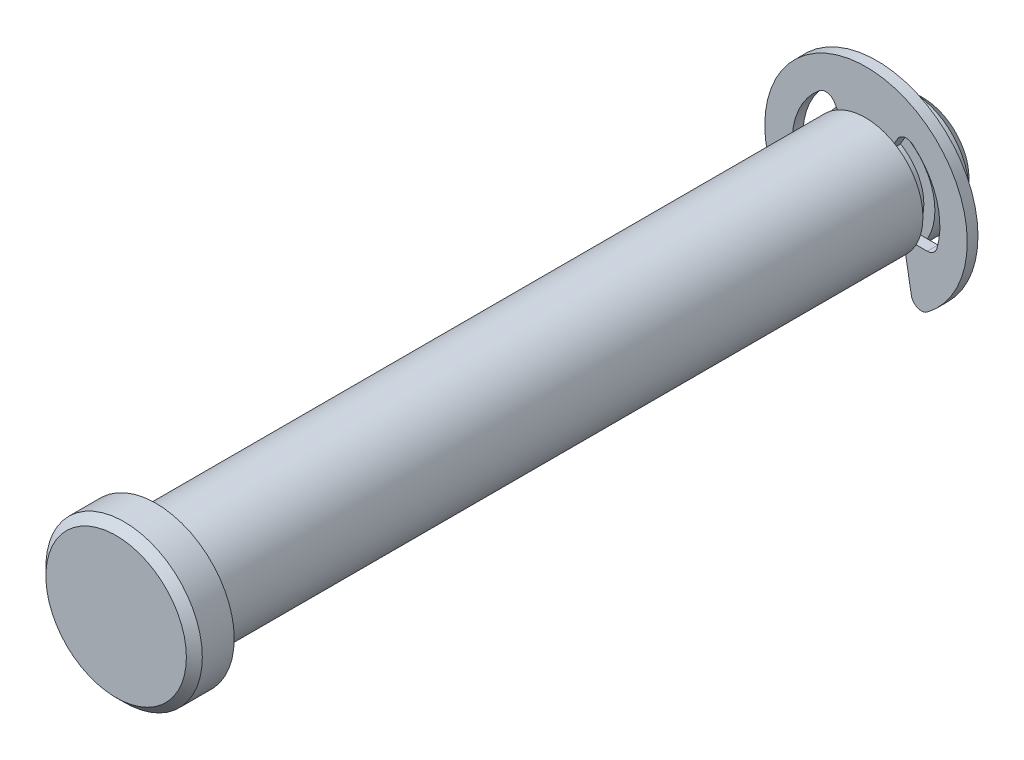
from build123d import *

# Parameters (mm, degrees)
SKETCH2_R      = 4.7625
EXTRUDE1_DEPTH = 31.75
SKETCH3_W      = 0.9906
SKETCH3_H      = 0.9144
SKETCH8_R      = 6.477
EXTRUDE6_DEPTH = 3.302
CHAMFER2_SIZE  = 0.6604
SKETCH4_R      = 8.382
SKETCH4_R_2    = 3.8481
EXTRUDE2_DEPTH = 0.4445
EXTRUDE4_DEPTH = 32.75
EXTRUDE5_DEPTH = 0.889
FILLET1_R      = 0.8382
CHAMFER1_SIZE  = 0.9525


with BuildPart() as part:
    # Sketch2 → Extrude1 (new body, symmetric)
    with BuildSketch(Plane.XY):
        Circle(SKETCH2_R)
    extrude(amount=EXTRUDE1_DEPTH, both=True)

    # Sketch3 → Cut-Revolve1 (revolve, cut)
    with BuildSketch(Plane(origin=(0, 0, 0), x_dir=(0, 0, -1), z_dir=(1, 0, 0))):
        with Locations((27.4828, 4.3053)):
            Rectangle(SKETCH3_W, SKETCH3_H)
    revolve(axis=Axis((0, 0, 31.75), (0, 0, -1)), mode=Mode.SUBTRACT)

    # Sketch8 → Extrude6 (add)
    with BuildSketch(Plane.XY.offset(31.75)):
        Circle(SKETCH8_R)
    extrude(amount=EXTRUDE6_DEPTH)

    # Chamfer2
    chamfer2_edges = [part.edges().sort_by_distance(p)[0] for p in [
        (-6.477, 0, 35.052),
    ]]
    chamfer(chamfer2_edges, length=CHAMFER2_SIZE)

    # Chamfer1
    chamfer1_edges = [part.edges().sort_by_distance(p)[0] for p in [
        (-4.7625, 0, -31.75),
    ]]
    chamfer(chamfer1_edges, length=CHAMFER1_SIZE)


with BuildPart() as body_2:
    # Sketch4 → Extrude2 (new body, symmetric)
    with BuildSketch(Plane.XY.offset(-27.4828)):
        Circle(SKETCH4_R)
        Circle(SKETCH4_R_2, mode=Mode.SUBTRACT)
    extrude(amount=EXTRUDE2_DEPTH, both=True)

    # Sketch5 → Extrude4 (cut, through all)
    with BuildSketch(Plane.XY):
        with BuildLine():
            Line((-3.057525, 5.295788645), (0, 0))
            Line((0, 0), (3.057525, 5.295788645))
            ThreePointArc((3.057525, 5.295788645), (5.785069674, 1.981616859), (5.662420154, -2.30886))
            Line((5.662420154, -2.30886), (3.07848, -2.30886))
            Line((3.07848, -2.30886), (3.972784338, -7.380711931))
            ThreePointArc((3.972784338, -7.380711931), (0, -8.382), (-3.972784338, -7.380711931))
            Line((-3.972784338, -7.380711931), (-3.07848, -2.30886))
            Line((-3.07848, -2.30886), (-5.662420154, -2.30886))
            ThreePointArc((-5.662420154, -2.30886), (-5.785069674, 1.981616859), (-3.057525, 5.295788645))
        make_face()
    extrude(amount=-EXTRUDE4_DEPTH, mode=Mode.SUBTRACT)

    # Sketch6 → Extrude5 (add)
    with BuildSketch(Plane.XY.offset(-27.0383)):
        with BuildLine():
            Line((-1.92405, 3.332552356), (1.92405, 3.332552356))
            ThreePointArc((1.92405, 3.332552356), (0, 3.8481), (-1.92405, 3.332552356))
        make_face()
    extrude(amount=-EXTRUDE5_DEPTH)

    # Fillet1
    fillet1_edges = [body_2.edges().sort_by_distance(p)[0] for p in [
        (3.057525, 5.295788645, -27.4828),
        (3.972784338, -7.380711931, -27.4828),
        (-5.662420154, -2.30886, -27.4828),
        (5.662420154, -2.30886, -27.4828),
        (-3.972784338, -7.380711931, -27.4828),
        (-3.057525, 5.295788645, -27.4828),
    ]]
    fillet(fillet1_edges, radius=FILLET1_R)


solid = Compound([part.part, body_2.part])
